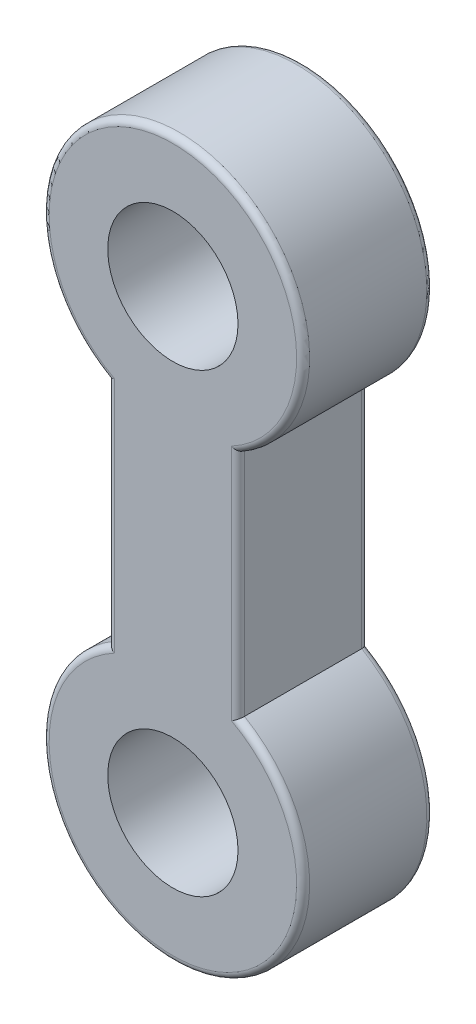
from build123d import *

# Parameters (mm, degrees)
ESQUISSE1_R        = 10
BOSS_EXTRU_1_DEPTH = 20
CONG_2_R           = 1


with BuildPart() as part:
    # Esquisse1 → Boss.-Extru.1 (new body)
    with BuildSketch(Plane.XY):
        with BuildLine():
            Line((-10, -17.320508076), (-10, -52.679491924))
            ThreePointArc((-10, -52.679491924), (0, -90), (10, -52.679491924))
            Line((10, -52.679491924), (10, -17.320508076))
            ThreePointArc((10, -17.320508076), (0, 20), (-10, -17.320508076))
        make_face()
        Circle(ESQUISSE1_R, mode=Mode.SUBTRACT)
        with Locations((0, -70)):
            Circle(ESQUISSE1_R, mode=Mode.SUBTRACT)
    extrude(amount=BOSS_EXTRU_1_DEPTH)

    # Congé2
    cong_2_edges = [part.edges().sort_by_distance(p)[0] for p in [
        (0, -90, 20),
        (10, -35, 20),
        (0, 20, 20),
        (10, -35, 0),
        (0, -90, 0),
        (-10, -35, 0),
        (0, 20, 0),
        (-10, -35, 20),
    ]]
    fillet(cong_2_edges, radius=CONG_2_R)


solid = part.part
